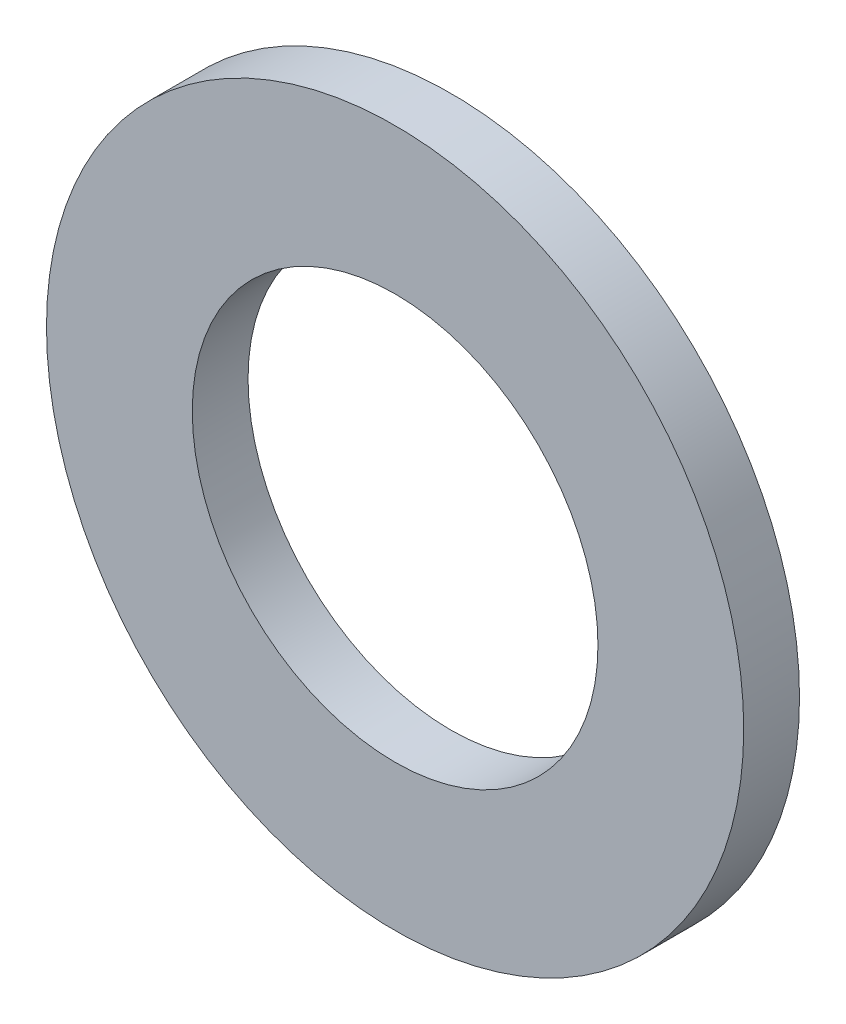
from build123d import *

# Parameters (mm, degrees)
SKETCH1_R           = 3.4925
SKETCH1_R_2         = 2.032
BOSS_EXTRUDE1_DEPTH = 0.2794


with BuildPart() as part:
    # Sketch1 → Boss-Extrude1 (new body, symmetric)
    with BuildSketch(Plane.XY):
        Circle(SKETCH1_R)
        Circle(SKETCH1_R_2, mode=Mode.SUBTRACT)
    extrude(amount=BOSS_EXTRUDE1_DEPTH, both=True)


solid = part.part
